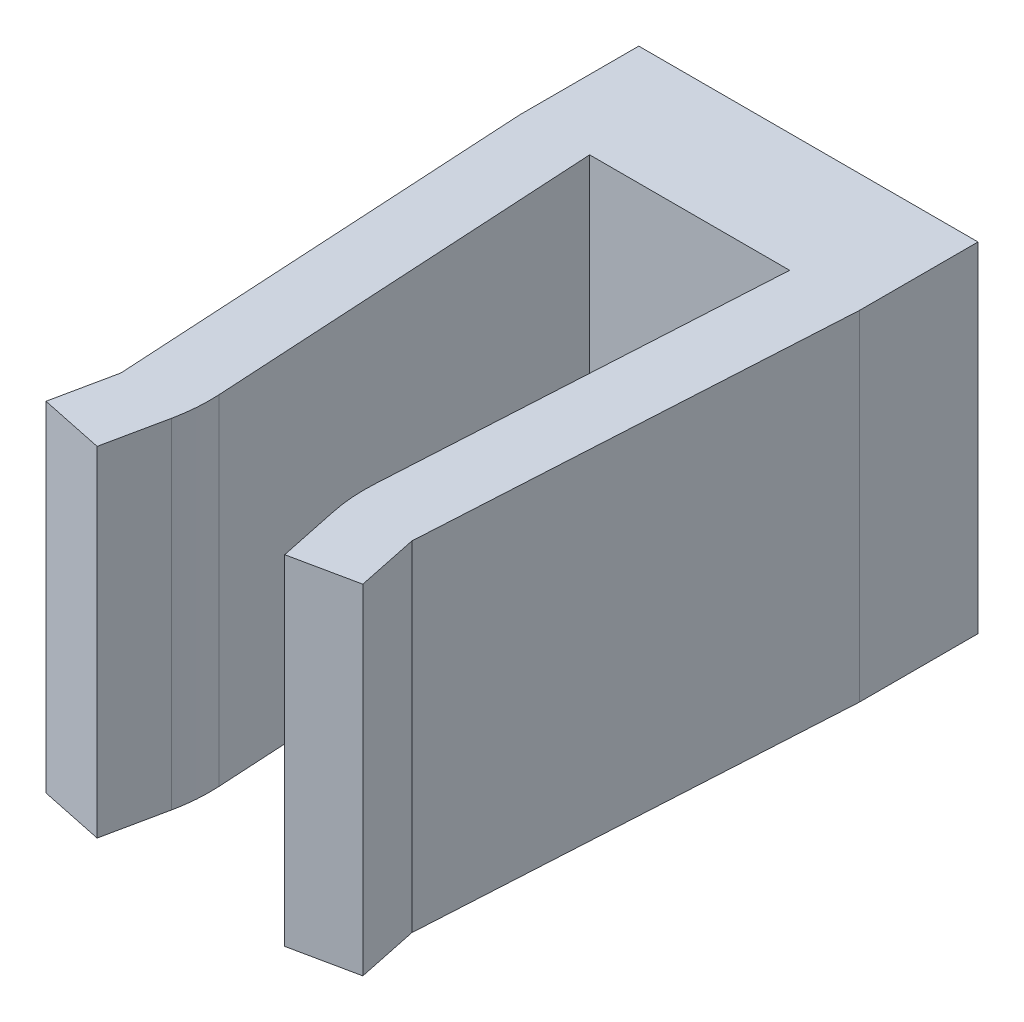
from build123d import *

# Parameters (mm, degrees)
SKETCH1_W           = 20
SKETCH1_H           = 20
BOSS_EXTRUDE1_DEPTH = 7
SKETCH2_R           = 2.75
CUT_EXTRUDE1_DEPTH  = 8
BOSS_EXTRUDE2_DEPTH = 20
FILLET1_R           = 10


with BuildPart() as part:
    # Sketch1 → Boss-Extrude1 (new body)
    with BuildSketch(Plane.XY):
        with Locations((10, -10)):
            Rectangle(SKETCH1_W, SKETCH1_H)
    extrude(amount=BOSS_EXTRUDE1_DEPTH)

    # Sketch2 → Cut-Extrude1 (cut, through all)
    with BuildSketch(Plane.XY.offset(7)):
        with Locations((10, -10)):
            Circle(SKETCH2_R)
    extrude(amount=-CUT_EXTRUDE1_DEPTH, mode=Mode.SUBTRACT)

    # Sketch3 → Boss-Extrude2 (add)
    with BuildSketch(Plane(origin=(0, 0, 0), x_dir=(1, 0, 0), z_dir=(0, 1, 0))):
        Polygon((0, -7), (1.423068417, -31.959464663), (0.659996677, -35.607013498), (4.47015192, -36.404102701), (5.5, -31.481339917), (4.104191952, -7), align=None)
        Polygon((15.895808048, -7), (20, -7), (18.576931583, -31.959464663), (19.340003323, -35.607013498), (15.52984808, -36.404102701), (14.5, -31.481339917), align=None)
    extrude(amount=-BOSS_EXTRUDE2_DEPTH)

    # Fillet1
    fillet1_edges = [part.edges().sort_by_distance(p)[0] for p in [
        (5.5, -10, 31.481339917),
        (14.5, -10, 31.481339917),
    ]]
    fillet(fillet1_edges, radius=FILLET1_R)


solid = part.part
